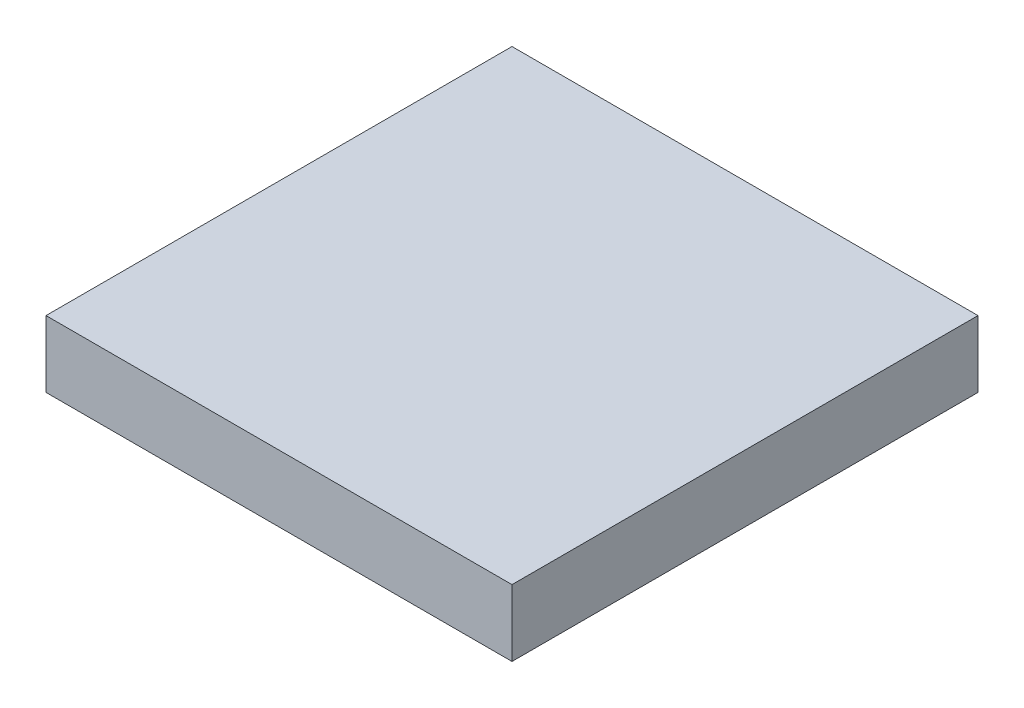
from build123d import *

# Parameters (mm, degrees)
SKETCH1_W           = 88.9
SKETCH1_H           = 88.9
BOSS_EXTRUDE1_DEPTH = 12.7


with BuildPart() as part:
    # Sketch1 → Boss-Extrude1 (new body)
    with BuildSketch(Plane(origin=(0, 0, 0), x_dir=(1, 0, 0), z_dir=(0, 1, 0))):
        with Locations((44.45, -44.45)):
            Rectangle(SKETCH1_W, SKETCH1_H)
    extrude(amount=BOSS_EXTRUDE1_DEPTH)


solid = part.part
